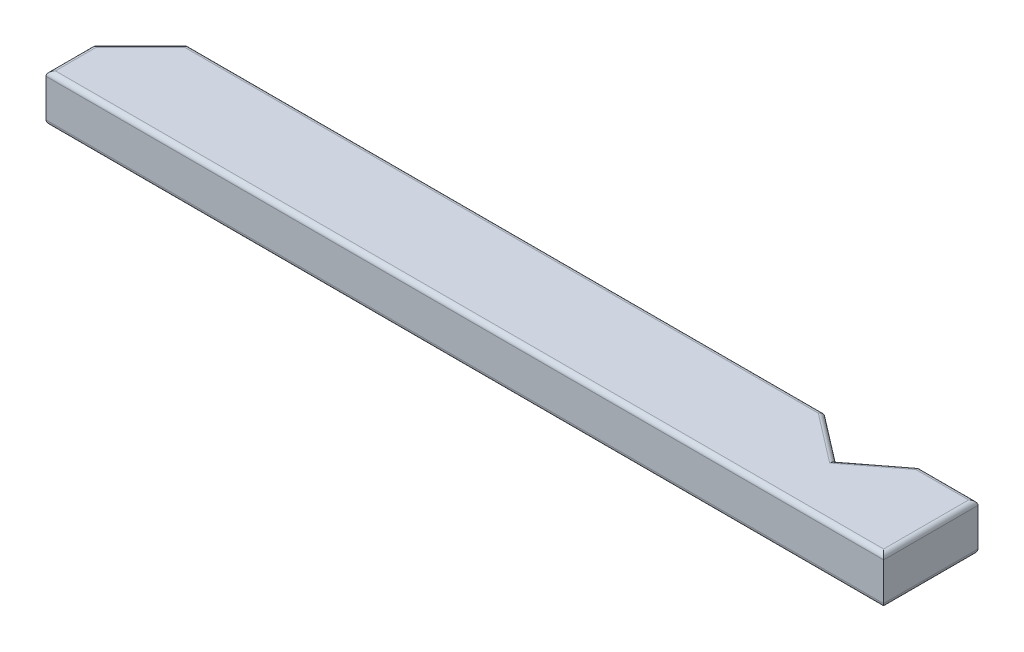
from build123d import *

# Parameters (mm, degrees)
SKETCH3_W           = 901.6
SKETCH3_H           = 101.6
BOSS_EXTRUDE3_DEPTH = 50.8
CUT_EXTRUDE1_DEPTH  = 51.8
FILLET1_R           = 5.08


with BuildPart() as part:
    # Sketch3 → Boss-Extrude3 (new body)
    with BuildSketch(Plane(origin=(0, -12.7, 0), x_dir=(-1, 0, 0), z_dir=(0, -1, 0))):
        with Locations((-2263.5, -338.5)):
            Rectangle(SKETCH3_W, SKETCH3_H)
    extrude(amount=-BOSS_EXTRUDE3_DEPTH)

    # Sketch4 → Cut-Extrude1 (cut, through all)
    with BuildSketch(Plane(origin=(0, 38.1, 0), x_dir=(1, 0, 0), z_dir=(0, 1, 0))):
        Polygon((2549.2, -287.7), (2600, -326.680210989), (2650.8, -287.7), align=None)
        Polygon((1812.7, -287.7), (1812.7, -338.5), (1863.5, -287.7), align=None)
    extrude(amount=-CUT_EXTRUDE1_DEPTH, mode=Mode.SUBTRACT)

    # Fillet1
    fillet1_edges = [part.edges().sort_by_distance(p)[0] for p in [
        (2714.3, 38.1, 338.5),
        (2206.35, -12.7, 287.7),
        (2682.55, -12.7, 287.7),
        (2263.5, 38.1, 389.3),
        (2206.35, 38.1, 287.7),
        (2682.55, 38.1, 287.7),
        (2625.4, -12.7, 307.190105495),
        (2574.6, -12.7, 307.190105495),
        (2574.6, 38.1, 307.190105495),
        (2625.4, 38.1, 307.190105495),
        (1838.1, -12.7, 313.1),
        (1838.1, 38.1, 313.1),
        (1812.7, 38.1, 363.9),
        (2263.5, -12.7, 389.3),
        (2714.3, -12.7, 338.5),
        (1812.7, -12.7, 363.9),
    ]]
    fillet(fillet1_edges, radius=FILLET1_R)


solid = part.part
